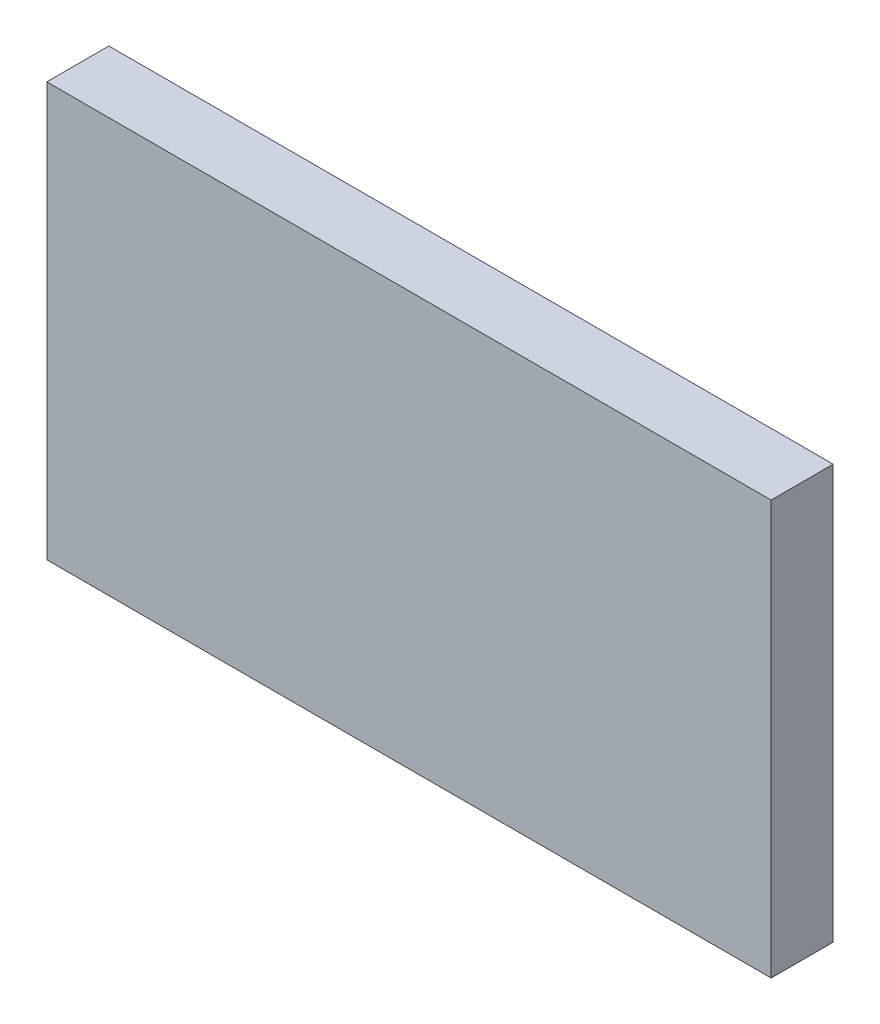
from build123d import *

# Parameters (mm, degrees)
ESQUISSE1_W        = 35
ESQUISSE1_H        = 20
BOSS_EXTRU_1_DEPTH = 3


with BuildPart() as part:
    # Esquisse1 → Boss.-Extru.1 (new body)
    with BuildSketch(Plane.XY):
        with Locations((-0.413605442, 1.14)):
            Rectangle(ESQUISSE1_W, ESQUISSE1_H)
    extrude(amount=BOSS_EXTRU_1_DEPTH)


solid = part.part
